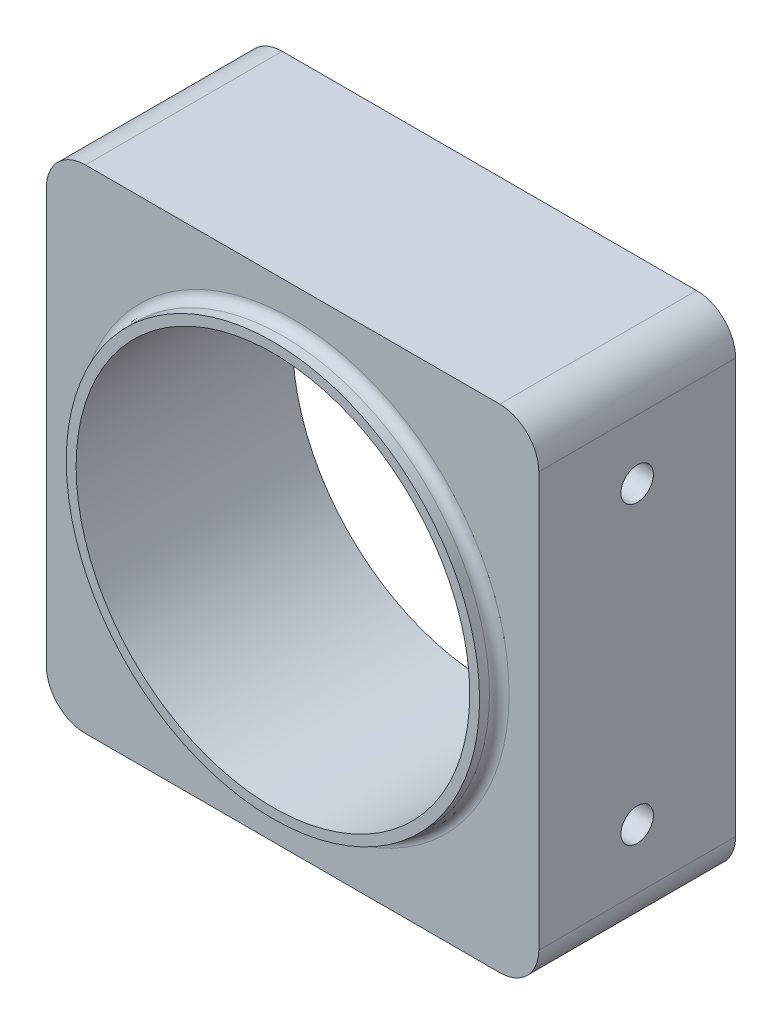
from build123d import *

# Parameters (mm, degrees)
SKETCH1_W                      = 50.038
SKETCH1_H                      = 50.038
SKETCH1_R                      = 20
BOSS_EXTRUDE1_DEPTH            = 20
FILLET1_R                      = 3.96875
M4X0_7_TAPPED_HOLE2_AT_2_COUNT = 2
M4X0_7_TAPPED_HOLE2_AT_2_PITCH = 30
SKETCH6_R                      = 21
SKETCH6_R_2                    = 20
BOSS_EXTRUDE2_DEPTH            = 2
FILLET2_R                      = 1


with BuildPart() as part:
    # Sketch1 → Boss-Extrude1 (new body)
    with BuildSketch(Plane.XY):
        Rectangle(SKETCH1_W, SKETCH1_H)
        Circle(SKETCH1_R, mode=Mode.SUBTRACT)
    extrude(amount=BOSS_EXTRUDE1_DEPTH)

    # Fillet1
    fillet1_edges = [part.edges().sort_by_distance(p)[0] for p in [
        (25.019, -25.019, 10),
        (-25.019, -25.019, 10),
        (-25.019, 25.019, 10),
        (25.019, 25.019, 10),
    ]]
    fillet(fillet1_edges, radius=FILLET1_R)

    # Sketch5 → M4x0.7 Tapped Hole2 (revolve, cut)
    with BuildSketch(Plane(origin=(-25.019, 15, 10), x_dir=(0, 0, 1), z_dir=(0, 1, 0))):
        Polygon((0, 0), (0, 8), (1.65, 7.008579979), (1.65, 0), align=None)
    m4x0_7_tapped_hole2 = revolve(axis=Axis((-31.369, 15, 10), (1, 0, 0)), mode=Mode.SUBTRACT)

    # M4x0.7 Tapped Hole2 at 2: M4x0.7 Tapped Hole2 ×2
    with Locations(*[(0, -i * M4X0_7_TAPPED_HOLE2_AT_2_PITCH, 0) for i in range(1, M4X0_7_TAPPED_HOLE2_AT_2_COUNT)]):
        add(m4x0_7_tapped_hole2, mode=Mode.SUBTRACT)

    # Mirror1: M4x0.7 Tapped Hole2 across plane
    add(m4x0_7_tapped_hole2.mirror(Plane(origin=(0, 0, 0), x_dir=(0, 0, 1), z_dir=(1, 0, 0))), mode=Mode.SUBTRACT)

    # Mirror1 copy 1 sketch → Mirror1 copy 1 (revolve, cut)
    with BuildSketch(Plane(origin=(25.019, -15, 10), x_dir=(0, 0, 1), z_dir=(0, 1, 0))):
        Polygon((0, 0), (0, -8), (1.65, -7.008579979), (1.65, 0), align=None)
    revolve(axis=Axis((31.369, -15, 10), (1, 0, 0)), mode=Mode.SUBTRACT)

    # Sketch6 → Boss-Extrude2 (add)
    with BuildSketch(Plane.XY.offset(20)):
        Circle(SKETCH6_R)
        Circle(SKETCH6_R_2, mode=Mode.SUBTRACT)
    extrude(amount=BOSS_EXTRUDE2_DEPTH)

    # Fillet2
    fillet2_edges = [part.edges().sort_by_distance(p)[0] for p in [
        (-21, 0, 20),
    ]]
    fillet(fillet2_edges, radius=FILLET2_R)


solid = part.part
